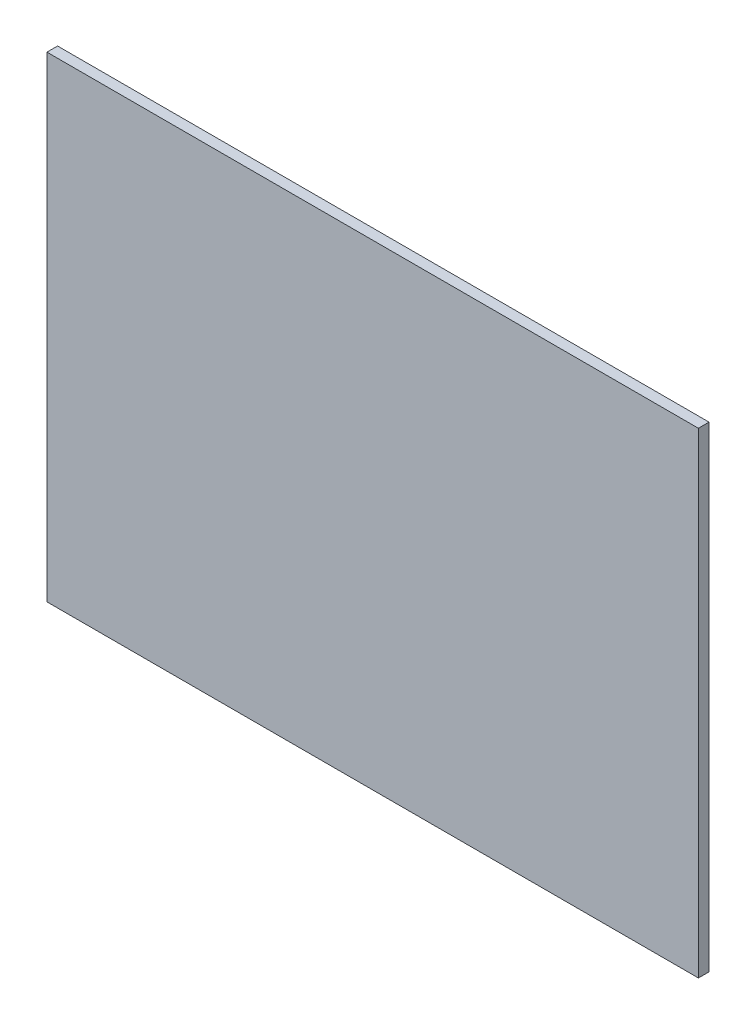
from build123d import *

# Parameters (mm, degrees)
SKETCH1_W           = 122.6
SKETCH1_H           = 89.6
BOSS_EXTRUDE1_DEPTH = 2


with BuildPart() as part:
    # Sketch1 → Boss-Extrude1 (new body)
    with BuildSketch(Plane.XY):
        Rectangle(SKETCH1_W, SKETCH1_H)
    extrude(amount=BOSS_EXTRUDE1_DEPTH)


solid = part.part
